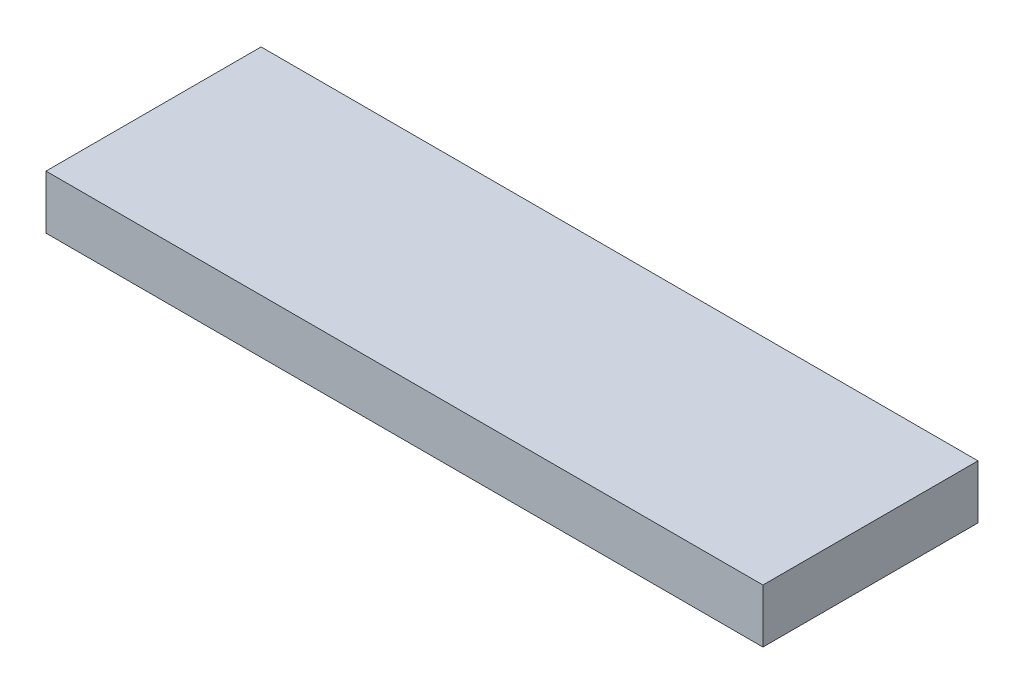
from build123d import *

# Parameters (mm, degrees)
SKETCH2_W           = 200
SKETCH2_H           = 60
BOSS_EXTRUDE2_DEPTH = 15


with BuildPart() as part:
    # Sketch2 → Boss-Extrude2 (new body)
    with BuildSketch(Plane(origin=(0, 0, 0), x_dir=(1, 0, 0), z_dir=(0, 1, 0))):
        Rectangle(SKETCH2_W, SKETCH2_H)
    extrude(amount=BOSS_EXTRUDE2_DEPTH)


solid = part.part
